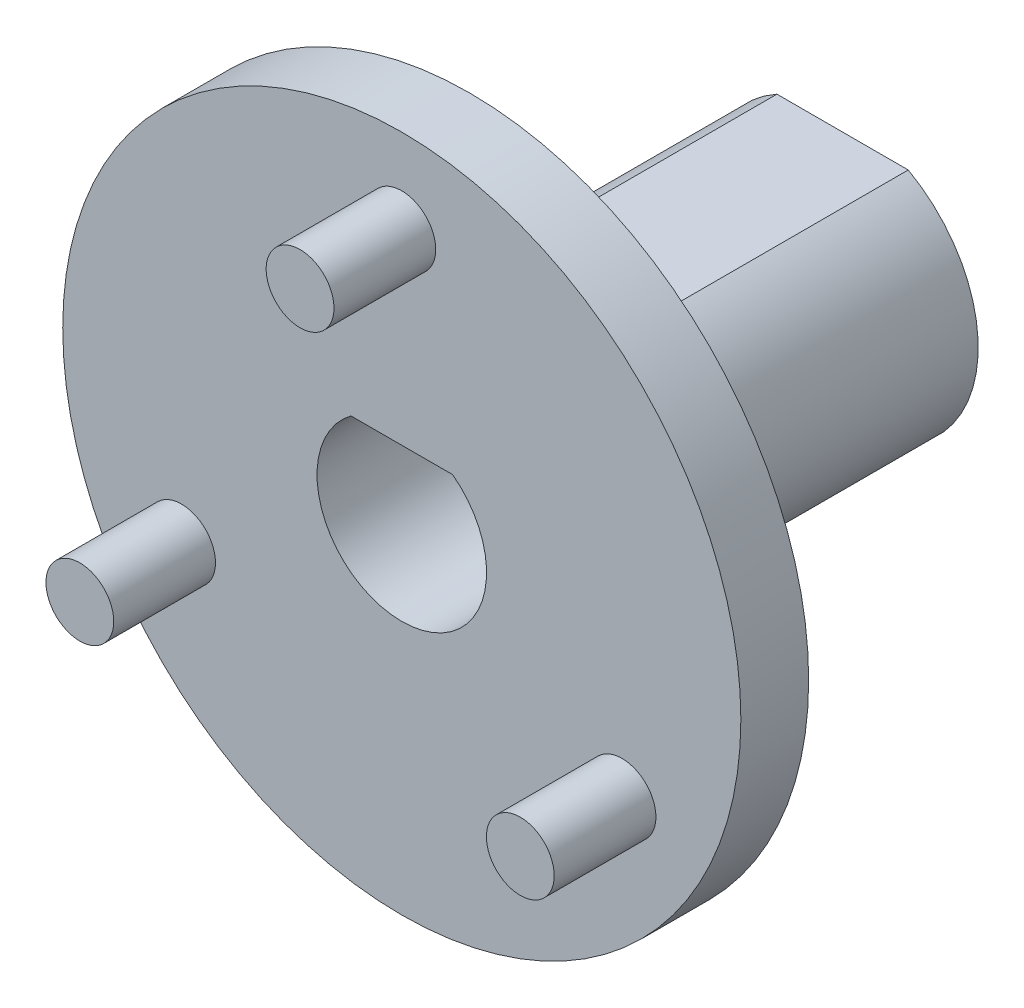
from build123d import *

# Parameters (mm, degrees)
SKETCH_1_R          = 1
EXTRUDE_1_DEPTH     = 3
EXTRUDE_1_2_DEPTH   = 3
EXTRUDE_1_3_DEPTH   = 3
SKETCH_2_R          = 10
EXTRUDE_2_DEPTH     = 2
SKETCH_3_R          = 5
EXTRUDE_3_DEPTH     = 1
EXTRUDE_4_DEPTH     = 10
CUT_EXTRUDE_1_DEPTH = 24


with BuildPart() as part:
    # 草图1 → 凸台-拉伸1 (new body)
    with BuildSketch(Plane.XY):
        with Locations((0, 7.5)):
            Circle(SKETCH_1_R)
    extrude(amount=EXTRUDE_1_DEPTH)


with BuildPart() as body_2:
    # 草图1 → Extrude 1 2 (new body)
    with BuildSketch(Plane.XY):
        with Locations((6.495190528, -3.75)):
            Circle(SKETCH_1_R)
    extrude(amount=EXTRUDE_1_2_DEPTH)


with BuildPart() as body_3:
    # 草图1 → Extrude 1 3 (new body)
    with BuildSketch(Plane.XY):
        with Locations((-6.495190528, -3.75)):
            Circle(SKETCH_1_R)
    extrude(amount=EXTRUDE_1_3_DEPTH)


with BuildPart() as body_4:
    # 草图2 → 凸台-拉伸2 (new body)
    with BuildSketch(Plane(origin=(0, 0, 0), x_dir=(-1, 0, 0), z_dir=(0, 0, -1))):
        Circle(SKETCH_2_R)
    extrude(amount=EXTRUDE_2_DEPTH)

    # 草图3 → 凸台-拉伸3 (add)
    with BuildSketch(Plane(origin=(0, 0, -2), x_dir=(-1, 0, 0), z_dir=(0, 0, -1))):
        Circle(SKETCH_3_R)
    extrude(amount=EXTRUDE_3_DEPTH)

    # 草图4 → 凸台-拉伸4 (add)
    with BuildSketch(Plane(origin=(0, 0, -3), x_dir=(-1, 0, 0), z_dir=(0, 0, -1))):
        with BuildLine():
            Line((-1.936491673, 3.5), (1.936491673, 3.5))
            ThreePointArc((1.936491673, 3.5), (0, -4), (-1.936491673, 3.5))
        make_face()
    extrude(amount=EXTRUDE_4_DEPTH)

    # 草图5 → 切除-拉伸1 (cut)
    with BuildSketch(Plane(origin=(0, 0, -13), x_dir=(-1, 0, 0), z_dir=(0, 0, -1))):
        with BuildLine():
            Line((-1.5, 2), (1.5, 2))
            ThreePointArc((1.5, 2), (0, -2.5), (-1.5, 2))
        make_face()
    extrude(amount=-CUT_EXTRUDE_1_DEPTH, mode=Mode.SUBTRACT)


solid = Compound([part.part, body_2.part, body_3.part, body_4.part])
